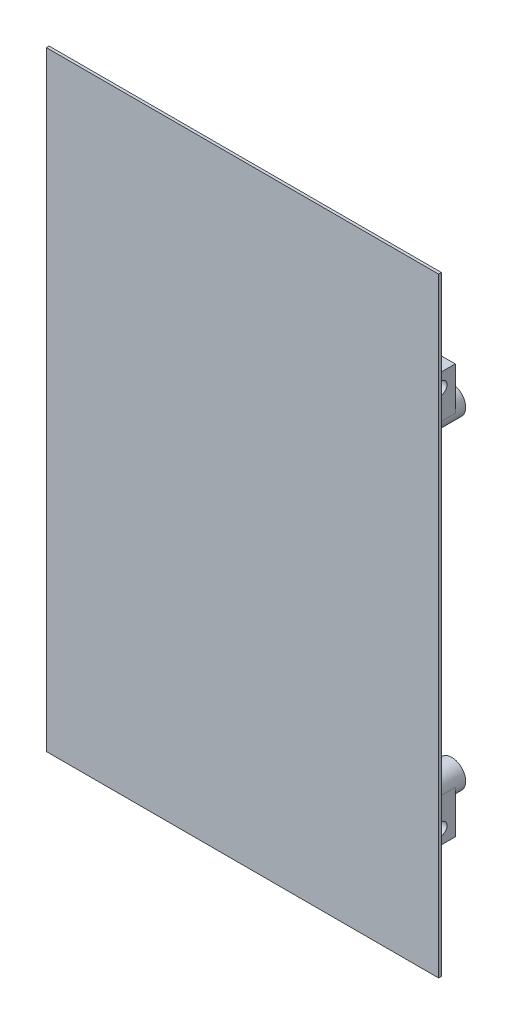
from build123d import *

# Parameters (mm, degrees)
SKETCH1_W           = 113
SKETCH1_H           = 175.618176042
BOSS_EXTRUDE1_DEPTH = 0.8
SKETCH2_R           = 4
SKETCH2_R_2         = 2
BOSS_EXTRUDE2_DEPTH = 11
CUT_EXTRUDE1_DEPTH  = 3.5
SKETCH4_W           = 5
SKETCH4_H           = 8
BOSS_EXTRUDE3_DEPTH = 8
SKETCH5_R           = 1.75
CUT_EXTRUDE2_DEPTH  = 105
CUT_EXTRUDE3_DEPTH  = 2.5


with BuildPart() as part:
    # Sketch1 → Boss-Extrude1 (new body)
    with BuildSketch(Plane.XY):
        with Locations((52.5, 73.5)):
            Rectangle(SKETCH1_W, SKETCH1_H)
    extrude(amount=BOSS_EXTRUDE1_DEPTH)

    # Sketch2 → Boss-Extrude2 (add)
    with BuildSketch(Plane(origin=(0, 0, 0), x_dir=(-1, 0, 0), z_dir=(0, 0, -1))):
        with Locations((-7.2, 120.15)):
            Circle(SKETCH2_R)
        with Locations((-7.2, 120.15)):
            Circle(SKETCH2_R_2, mode=Mode.SUBTRACT)
        with Locations((-7.2, 26.85)):
            Circle(SKETCH2_R)
        with Locations((-7.2, 26.85)):
            Circle(SKETCH2_R_2, mode=Mode.SUBTRACT)
        with Locations((-101, 26.85)):
            Circle(SKETCH2_R)
        with Locations((-101, 26.85)):
            Circle(SKETCH2_R_2, mode=Mode.SUBTRACT)
        with Locations((-101, 120.15)):
            Circle(SKETCH2_R)
        with Locations((-101, 120.15)):
            Circle(SKETCH2_R_2, mode=Mode.SUBTRACT)
    extrude(amount=BOSS_EXTRUDE2_DEPTH)

    # Sketch3 → Cut-Extrude1 (cut)
    with BuildSketch(Plane(origin=(0, 0, 0), x_dir=(-1, 0, 0), z_dir=(0, 0, -1))):
        Polygon((-5.467949192, 123.15), (-8.932050808, 123.15), (-10.664101615, 120.15), (-8.932050808, 117.15), (-5.467949192, 117.15), (-3.735898385, 120.15), align=None)
        with BuildLine():
            Line((-10.664101615, 120.15), (-8.932050808, 123.15))
            Line((-8.932050808, 123.15), (-9.845751311, 123.15))
            ThreePointArc((-9.845751311, 123.15), (-11.2, 120.15), (-9.845751311, 117.15))
            Line((-9.845751311, 117.15), (-8.932050808, 117.15))
            Line((-8.932050808, 117.15), (-10.664101615, 120.15))
        make_face()
        Polygon((-102.732050808, 117.15), (-99.267949192, 117.15), (-97.535898385, 120.15), (-99.267949192, 123.15), (-102.732050808, 123.15), (-104.464101615, 120.15), align=None)
        with BuildLine():
            Line((-98.354248689, 123.15), (-99.267949192, 123.15))
            Line((-99.267949192, 123.15), (-97.535898385, 120.15))
            Line((-97.535898385, 120.15), (-99.267949192, 117.15))
            Line((-99.267949192, 117.15), (-98.354248689, 117.15))
            ThreePointArc((-98.354248689, 117.15), (-97.354248689, 118.504248689), (-97, 120.15))
            ThreePointArc((-97, 120.15), (-97.354248689, 121.795751311), (-98.354248689, 123.15))
        make_face()
        with BuildLine():
            Line((-99.267949192, 29.85), (-97.535898385, 26.85))
            Line((-97.535898385, 26.85), (-99.267949192, 23.85))
            Line((-99.267949192, 23.85), (-98.354248689, 23.85))
            ThreePointArc((-98.354248689, 23.85), (-97.354248689, 25.204248689), (-97, 26.85))
            ThreePointArc((-97, 26.85), (-97.354248689, 28.495751311), (-98.354248689, 29.85))
            Line((-98.354248689, 29.85), (-99.267949192, 29.85))
        make_face()
        Polygon((-102.732050808, 23.85), (-99.267949192, 23.85), (-97.535898385, 26.85), (-99.267949192, 29.85), (-102.732050808, 29.85), (-104.464101615, 26.85), align=None)
        Polygon((-5.467949192, 23.85), (-8.932050808, 23.85), (-10.664101615, 26.85), (-8.932050808, 29.85), (-5.467949192, 29.85), (-3.735898385, 26.85), align=None)
        with BuildLine():
            Line((-10.664101615, 26.85), (-8.932050808, 29.85))
            Line((-8.932050808, 29.85), (-9.845751311, 29.85))
            ThreePointArc((-9.845751311, 29.85), (-11.2, 26.85), (-9.845751311, 23.85))
            Line((-9.845751311, 23.85), (-8.932050808, 23.85))
            Line((-8.932050808, 23.85), (-10.664101615, 26.85))
        make_face()
    extrude(amount=CUT_EXTRUDE1_DEPTH, mode=Mode.SUBTRACT)

    # Sketch4 → Boss-Extrude3 (add)
    with BuildSketch(Plane(origin=(0, 0, 0), x_dir=(-1, 0, 0), z_dir=(0, 0, -1))):
        with Locations((-102.5, 18.5)):
            Rectangle(SKETCH4_W, SKETCH4_H)
        with BuildLine():
            Line((-105, 26.85), (-105, 22.5))
            Line((-105, 22.5), (-100, 22.5))
            Line((-100, 22.5), (-100, 22.977016654))
            ThreePointArc((-100, 22.977016654), (-103.449489743, 23.68772234), (-105, 26.85))
        make_face()
        with BuildLine():
            Line((-105, 124.5), (-105, 120.15))
            ThreePointArc((-105, 120.15), (-103.449489743, 123.31227766), (-100, 124.022983346))
            Line((-100, 124.022983346), (-100, 124.5))
            Line((-100, 124.5), (-105, 124.5))
        make_face()
        with Locations((-102.5, 128.5)):
            Rectangle(SKETCH4_W, SKETCH4_H)
        with BuildLine():
            Line((-3.2, 120.15), (-3.2, 124.5))
            Line((-3.2, 124.5), (-5, 124.5))
            Line((-5, 124.5), (-5, 123.490658618))
            ThreePointArc((-5, 123.490658618), (-3.678636628, 122.047366596), (-3.2, 120.15))
        make_face()
        with Locations((-2.5, 128.5)):
            Rectangle(SKETCH4_W, SKETCH4_H)
        Polygon((-5, 14.5), (0, 14.5), (0, 22.5), (-3.2, 22.5), (-5, 22.5), align=None)
        with BuildLine():
            Line((-5, 23.509341382), (-5, 22.5))
            Line((-5, 22.5), (-3.2, 22.5))
            Line((-3.2, 22.5), (-3.2, 26.85))
            ThreePointArc((-3.2, 26.85), (-3.678636628, 24.952633404), (-5, 23.509341382))
        make_face()
    extrude(amount=BOSS_EXTRUDE3_DEPTH)

    # Sketch5 → Cut-Extrude2 (cut)
    with BuildSketch(Plane.ZY.offset(-105)):
        with Locations((-3.896353455, 128.5)):
            Circle(SKETCH5_R)
        with Locations((-3.896353455, 18.5)):
            Circle(SKETCH5_R)
    extrude(amount=CUT_EXTRUDE2_DEPTH, mode=Mode.SUBTRACT)

    # Sketch6 → Cut-Extrude3 (cut)
    with BuildSketch(Plane.ZY.offset(-100)):
        Polygon((-3.896353455, 21.964101615), (-6.896353455, 20.232050808), (-6.896353455, 16.767949192), (-3.896353455, 15.035898385), (-0.896353455, 16.767949192), (-0.896353455, 20.232050808), align=None)
        Polygon((-0.896353455, 130.232050808), (-0.896353455, 126.767949192), (-3.896353455, 125.035898385), (-6.896353455, 126.767949192), (-6.896353455, 130.232050808), (-3.896353455, 131.964101615), align=None)
    cut_extrude3 = extrude(amount=-CUT_EXTRUDE3_DEPTH, mode=Mode.SUBTRACT)

    # Mirror1: Cut-Extrude3 across plane
    add(cut_extrude3.mirror(Plane.ZY.offset(-52.5)), mode=Mode.SUBTRACT)


solid = part.part
